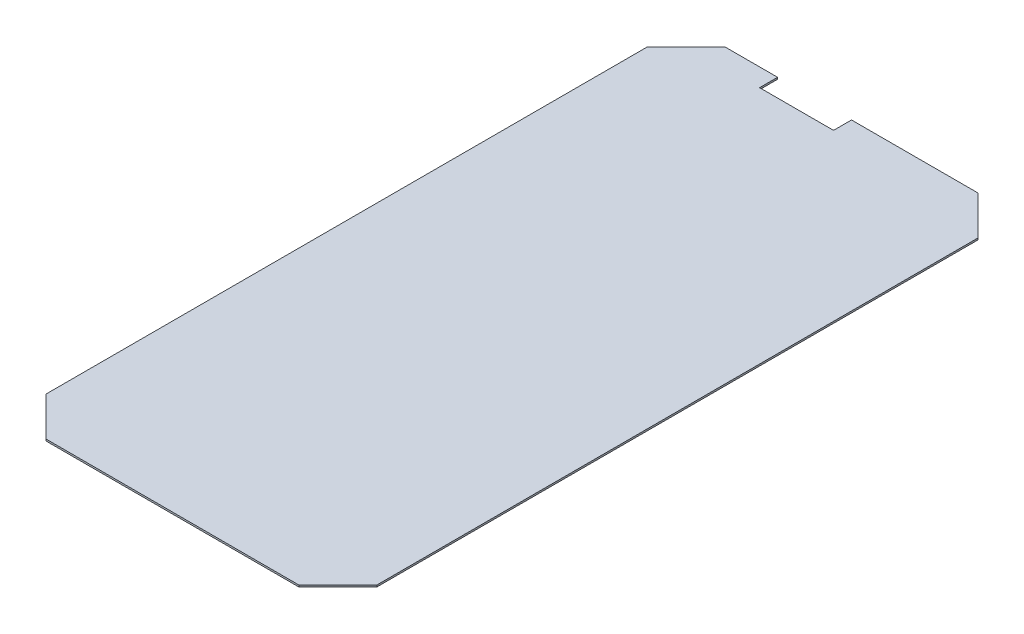
from build123d import *

# Parameters (mm, degrees)
SKETCH1_W           = 34
SKETCH1_H           = 69.8
BOSS_EXTRUDE1_DEPTH = 0.18
CHAMFER1_SIZE       = 4
SKETCH2_W           = 7.6
SKETCH2_H           = 1.85
CUT_EXTRUDE1_DEPTH  = 39.820643993


with BuildPart() as part:
    # Sketch1 → Boss-Extrude1 (new body)
    with BuildSketch(Plane(origin=(0, 0, 0), x_dir=(1, 0, 0), z_dir=(0, 1, 0))):
        Rectangle(SKETCH1_W, SKETCH1_H)
    extrude(amount=BOSS_EXTRUDE1_DEPTH)

    # Chamfer1
    chamfer1_edges = [part.edges().sort_by_distance(p)[0] for p in [
        (-17, 0.09, 34.9),
        (17, 0.09, -34.9),
        (-17, 0.09, -34.9),
        (17, 0.09, 34.9),
    ]]
    chamfer(chamfer1_edges, length=CHAMFER1_SIZE)

    # Sketch2 → Cut-Extrude1 (cut, through all)
    with BuildSketch(Plane(origin=(0, 0.18, 0), x_dir=(1, 0, 0), z_dir=(0, 1, 0))):
        with Locations((-3.8, 33.975)):
            Rectangle(SKETCH2_W, SKETCH2_H)
    extrude(amount=-CUT_EXTRUDE1_DEPTH, mode=Mode.SUBTRACT)


solid = part.part
